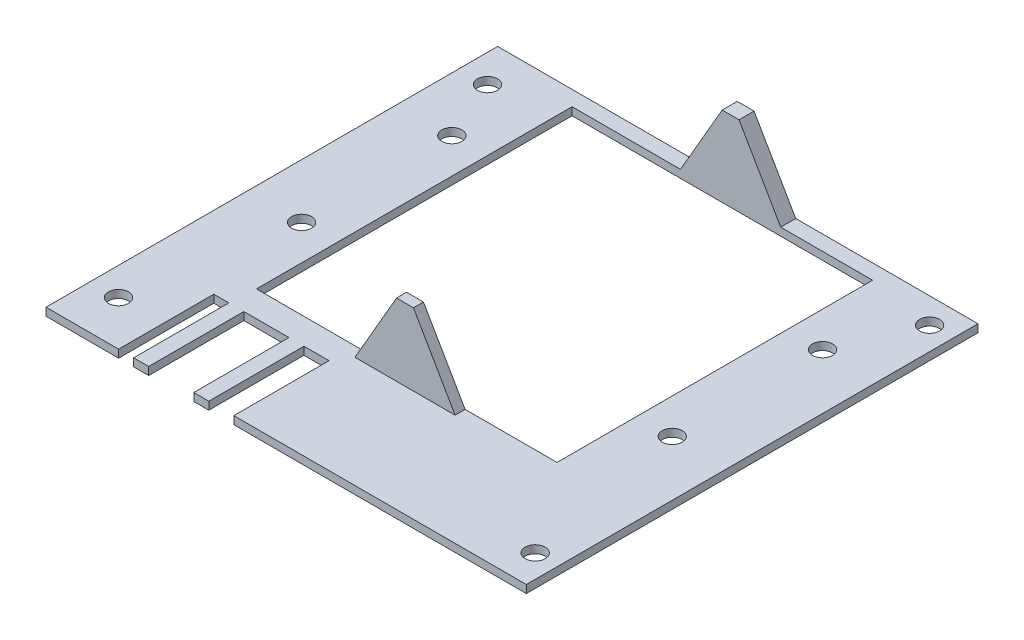
from build123d import *

# Parameters (mm, degrees)
SKETCH1_W               = 96.89
SKETCH1_H               = 90.17
PCB_DEPTH               = 1.57
SKETCH2_R               = 2
M3_MOUNTING_HOLES_DEPTH = 1.57
SKETCH4_R               = 2
CUT_EXTRUDE1_DEPTH      = 23
BOSS_EXTRUDE2_DEPTH     = 2
BOSS_EXTRUDE3_DEPTH     = 3
SKETCH9_W               = 3
SKETCH9_H               = 19
SKETCH9_W_2             = 9
SKETCH9_W_3             = 5
CUT_EXTRUDE2_DEPTH      = 2.57
SKETCH10_W              = 0.5
SKETCH10_H              = 90.17
CUT_EXTRUDE3_DEPTH      = 10
SKETCH11_W              = 60
SKETCH11_H              = 63
CUT_EXTRUDE4_DEPTH      = 10


with BuildPart() as part:
    # Sketch1 → PCB (new body)
    with BuildSketch(Plane(origin=(0, 0, 0), x_dir=(1, 0, 0), z_dir=(0, 1, 0))):
        with Locations((16.200949951, 63.633996534)):
            Rectangle(SKETCH1_W, SKETCH1_H)
    extrude(amount=PCB_DEPTH)

    # Sketch2 → M3 Mounting Holes (cut)
    with BuildSketch(Plane(origin=(0, 1.57, 0), x_dir=(1, 0, 0), z_dir=(0, 1, 0))):
        with Locations((59.565949951, 24.898996534)):
            Circle(SKETCH2_R)
        with Locations((-26.164050049, 27.438996534)):
            Circle(SKETCH2_R)
        with Locations((-26.164050049, 101.098996534)):
            Circle(SKETCH2_R)
        with Locations((59.565949951, 103.638996534)):
            Circle(SKETCH2_R)
    extrude(amount=-M3_MOUNTING_HOLES_DEPTH, mode=Mode.SUBTRACT)

    # Sketch4 → Cut-Extrude1 (cut)
    with BuildSketch(Plane(origin=(0, 1.57, 0), x_dir=(1, 0, 0), z_dir=(0, 1, 0))):
        with Locations((-20.894050049, 88.718996534)):
            Circle(SKETCH4_R)
        with Locations((53.105949951, 88.718996534)):
            Circle(SKETCH4_R)
        with Locations((-20.894050049, 58.718996534)):
            Circle(SKETCH4_R)
        with Locations((53.105949951, 58.718996534)):
            Circle(SKETCH4_R)
    extrude(amount=-CUT_EXTRUDE1_DEPTH, mode=Mode.SUBTRACT)

    # Sketch7 → Boss-Extrude2 (add)
    with BuildSketch(Plane.XY.offset(-42.718996534)):
        Polygon((27.755949951, 1.57), (19.438412086, 15.976398176), (16.073487816, 15.976398176), (7.755949951, 1.57), align=None)
    extrude(amount=BOSS_EXTRUDE2_DEPTH)

    # Sketch8 → Boss-Extrude3 (add)
    with BuildSketch(Plane.XY.offset(-108.718996534)):
        Polygon((27.755949951, 1.57), (19.438412086, 15.976398176), (16.073487816, 15.976398176), (7.755949951, 1.57), align=None)
    extrude(amount=BOSS_EXTRUDE3_DEPTH)

    # Sketch9 → Cut-Extrude2 (cut, through all)
    with BuildSketch(Plane(origin=(0, 1.57, 0), x_dir=(1, 0, 0), z_dir=(0, 1, 0))):
        with Locations((-15.744050049, 28.048996534)):
            Rectangle(SKETCH9_W, SKETCH9_H)
        with Locations((-6.744050049, 28.048996534)):
            Rectangle(SKETCH9_W_2, SKETCH9_H)
        with Locations((3.255949951, 28.048996534)):
            Rectangle(SKETCH9_W_3, SKETCH9_H)
    extrude(amount=-CUT_EXTRUDE2_DEPTH, mode=Mode.SUBTRACT)

    # Sketch10 → Cut-Extrude3 (cut)
    with BuildSketch(Plane(origin=(0, 1.57, 0), x_dir=(1, 0, 0), z_dir=(0, 1, 0))):
        with Locations((-31.994050049, 63.633996534)):
            Rectangle(SKETCH10_W, SKETCH10_H)
        with Locations((64.395949951, 63.633996534)):
            Rectangle(SKETCH10_W, SKETCH10_H)
    extrude(amount=-CUT_EXTRUDE3_DEPTH, mode=Mode.SUBTRACT)

    # Sketch11 → Cut-Extrude4 (cut)
    with BuildSketch(Plane(origin=(0, 1.57, 0), x_dir=(1, 0, 0), z_dir=(0, 1, 0))):
        with Locations((16.105949951, 74.218996534)):
            Rectangle(SKETCH11_W, SKETCH11_H)
    extrude(amount=-CUT_EXTRUDE4_DEPTH, mode=Mode.SUBTRACT)


solid = part.part
